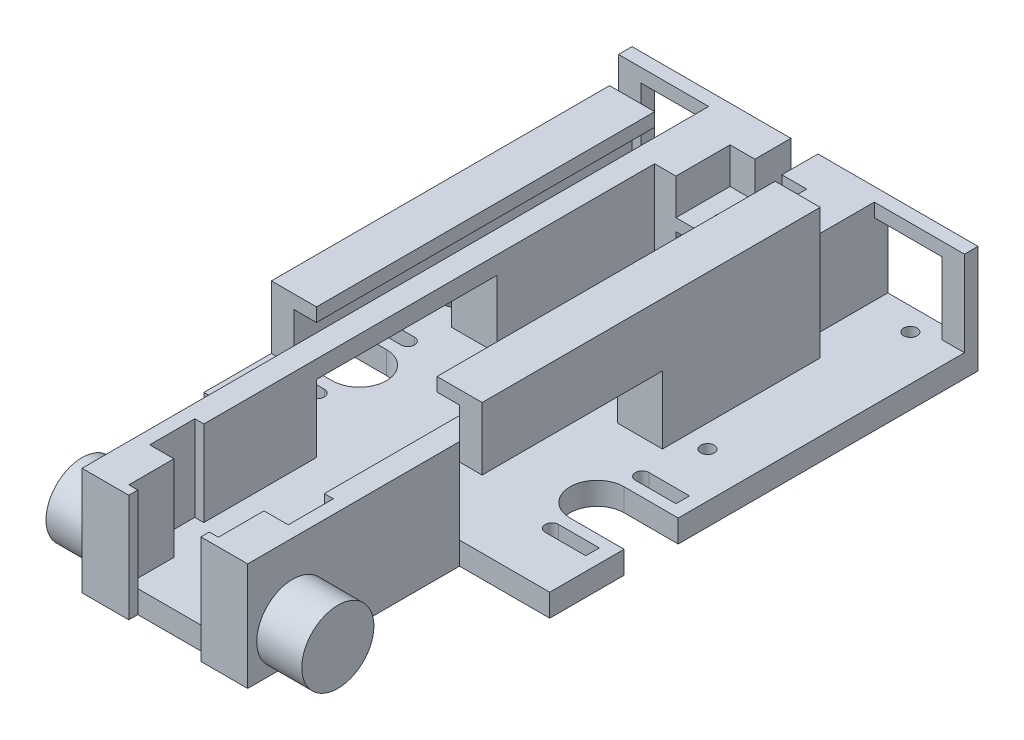
from build123d import *

# Parameters (mm, degrees)
BOSS_EXTRUDE1_DEPTH      = 203.2
SKETCH8_W                = 6.35
SKETCH8_H                = 30.4038
BOSS_EXTRUDE9_DEPTH      = 6.35
BOSS_EXTRUDE10_REACH     = 42.31
SKETCH9_W                = 6.35
SKETCH9_H                = 30.4038
SKETCH4_W                = 6.35
SKETCH4_H                = 30.4038
BOSS_EXTRUDE11_DEPTH     = 6.35
BOSS_EXTRUDE12_REACH     = 42.31
SKETCH10_W               = 6.35
SKETCH10_H               = 30.4038
SKETCH13_W               = 50.8
SKETCH13_H               = 19.05
CUT_EXTRUDE3_DEPTH       = 47.6598
SKETCH14_W               = 44.45
SKETCH14_H               = 6.35
BOSS_EXTRUDE13_DEPTH     = 25.4
SKETCH15_W               = 50.8
SKETCH15_H               = 6.35
BOSS_EXTRUDE14_DEPTH     = 25.4
SKETCH20_W               = 46.6598
SKETCH20_H               = 10.16
CUT_EXTRUDE6_DEPTH       = 6.35
SKETCH28_W               = 25.4
SKETCH28_H               = 6.35
BOSS_EXTRUDE16_DEPTH     = 6.35
SKETCH29_R               = 7.62
CUT_EXTRUDE7_DEPTH       = 6.35
CUT_EXTRUDE8_DEPTH       = 6.35
SKETCH32_R               = 10.16
BOSS_EXTRUDE17_DEPTH     = 12.7
SKETCH33_R               = 10.16
BOSS_EXTRUDE18_DEPTH     = 12.7
SKETCH34_W               = 51.260240893
SKETCH34_H               = 44.363692544
CUT_EXTRUDE9_DEPTH       = 63.5
SKETCH35_W               = 46.6598
SKETCH35_H               = 30.4038
BOSS_EXTRUDE19_DEPTH     = 6.35
SKETCH36_W               = 21.59
SKETCH36_H               = 10.16
CUT_EXTRUDE10_DEPTH      = 6.35
SKETCH37_W               = 25.4
SKETCH37_H               = 6.35
BOSS_EXTRUDE20_DEPTH     = 12.7
SKETCH38_R               = 1.905
CUT_EXTRUDE11_DEPTH      = 12.7
SKETCH44_R               = 1.143
CUT_EXTRUDE15_DEPTH      = 11.16
CUT_EXTRUDE15_DEPTH_BACK = 21.2438
CUT_EXTRUDE13_DEPTH      = 8.35
CUT_EXTRUDE14_DEPTH      = 24.0538
SKETCH47_R               = 3.556
CUT_EXTRUDE16_DEPTH      = 31.4038
CUT_EXTRUDE17_DEPTH      = 13.8938
SKETCH49_W               = 101.6
SKETCH49_H               = 5.0038
BOSS_EXTRUDE23_DEPTH     = 6.35
SKETCH50_W               = 101.6
SKETCH50_H               = 5.0038
BOSS_EXTRUDE24_DEPTH     = 6.35
SKETCH51_R               = 4.7625
SKETCH51_R_2             = 3.556
CUT_EXTRUDE18_DEPTH      = 3.556
SKETCH52_W               = 6.35
SKETCH52_H               = 101.6
SKETCH52_W_2             = 9.525
BOSS_EXTRUDE25_DEPTH     = 15.24
SKETCH53_W               = 59.3598
SKETCH53_H               = 82.55
BOSS_EXTRUDE26_DEPTH     = 3.175
SKETCH54_W               = 6.35
SKETCH54_H               = 20.2438
CUT_EXTRUDE20_DEPTH      = 19.05
SKETCH55_W               = 3.175
SKETCH55_H               = 15.24
CUT_EXTRUDE21_DEPTH      = 101.6
CUT_EXTRUDE23_DEPTH      = 6.35
CUT_EXTRUDE25_DEPTH      = 19.05
SKETCH58_W               = 2.54
SKETCH58_H               = 30.4038
BOSS_EXTRUDE27_DEPTH     = 2.54
SKETCH59_W               = 2.54
SKETCH59_H               = 30.4038
BOSS_EXTRUDE28_DEPTH     = 2.54
SKETCH60_W               = 2.370079739
SKETCH60_H               = 30.4038
BOSS_EXTRUDE29_DEPTH     = 2.54
SKETCH61_W               = 2.54
SKETCH61_H               = 30.4038
BOSS_EXTRUDE30_DEPTH     = 8.0899
SKETCH62_W               = 2.54
SKETCH62_H               = 30.4038
BOSS_EXTRUDE31_DEPTH     = 8.0899
SKETCH63_W               = 4.2799
SKETCH63_H               = 24.0538
BOSS_EXTRUDE32_DEPTH     = 6.35
SKETCH64_W               = 2.54
SKETCH64_H               = 12.7
CUT_EXTRUDE26_DEPTH      = 24.0538
BOSS_EXTRUDE34_DEPTH     = 19.05
SKETCH66_W               = 59.3598
SKETCH66_H               = 63.5
CUT_EXTRUDE27_DEPTH      = 18.415
SKETCH67_W               = 6.35
SKETCH67_H               = 12.7
BOSS_EXTRUDE35_DEPTH     = 19.05
SKETCH68_W               = 6.35
SKETCH68_H               = 12.7
BOSS_EXTRUDE36_DEPTH     = 19.05
SKETCH69_W               = 6.35
SKETCH69_H               = 63.5
BOSS_EXTRUDE39_DEPTH     = 12.7
SKETCH70_W               = 63.5
SKETCH70_H               = 3.81
BOSS_EXTRUDE40_DEPTH     = 6.35
SKETCH71_W               = 63.5
SKETCH71_H               = 3.81
BOSS_EXTRUDE41_DEPTH     = 6.35
SKETCH72_R               = 1.086486674
SKETCH72_R_2             = 1.143
CUT_EXTRUDE29_DEPTH      = 21.2438
SKETCH73_R               = 1.143
BOSS_EXTRUDE42_DEPTH     = 20.2438
SKETCH74_W               = 21.59
SKETCH74_H               = 1.6
CUT_EXTRUDE30_DEPTH      = 10.16
SKETCH75_W               = 46.6598
SKETCH75_H               = 30.4038
BOSS_EXTRUDE43_DEPTH     = 10.16
CUT_EXTRUDE32_DEPTH      = 10.16
SKETCH78_W               = 25.4
SKETCH78_H               = 6.35
BOSS_EXTRUDE44_DEPTH     = 57.15
SKETCH79_R               = 1.905
CUT_EXTRUDE33_DEPTH      = 37.7538
CUT_EXTRUDE33_DEPTH_BACK = 7.35
SKETCH80_W               = 44.45
SKETCH80_H               = 6.35
CUT_EXTRUDE34_DEPTH      = 25.4
SKETCH81_W               = 44.45
SKETCH81_H               = 6.35
CUT_EXTRUDE35_DEPTH      = 25.4
SKETCH82_W               = 6.35
SKETCH82_H               = 3.81
BOSS_EXTRUDE47_DEPTH     = 24.0538
SKETCH83_W               = 3.81
SKETCH83_H               = 3.81
BOSS_EXTRUDE48_DEPTH     = 19.05
SKETCH84_W               = 3.81
SKETCH84_H               = 3.81
BOSS_EXTRUDE49_DEPTH     = 19.05
SKETCH85_W               = 25.4
SKETCH85_H               = 6.35
BOSS_EXTRUDE50_DEPTH     = 44.45
SKETCH86_W               = 25.4
SKETCH86_H               = 6.35
BOSS_EXTRUDE51_DEPTH     = 44.45
BOSS_EXTRUDE52_DEPTH     = 31.75


with BuildPart() as part:
    # Sketch1 → Boss-Extrude1 (new body)
    with BuildSketch(Plane.XY):
        Polygon((0, 0), (33.9598, 0), (33.9598, 24.0538), (40.3098, 24.0538), (40.3098, -6.35), (-6.35, -6.35), (-6.35, 24.0538), (0, 24.0538), align=None)
    extrude(amount=-BOSS_EXTRUDE1_DEPTH)

    # Sketch8 → Boss-Extrude9 (add)
    with BuildSketch(Plane(origin=(0, 0, -203.2), x_dir=(-1, 0, 0), z_dir=(0, 0, -1))):
        with Locations((-37.1348, 8.8519)):
            Rectangle(SKETCH8_W, SKETCH8_H)
        with Locations((3.175, 8.8519)):
            Rectangle(SKETCH8_W, SKETCH8_H)
    extrude(amount=BOSS_EXTRUDE9_DEPTH)

    # Sketch9 → Boss-Extrude10 (add, up to next)
    with BuildSketch(Plane(origin=(0, 0, 0), x_dir=(0, 0, -1), z_dir=(1, 0, 0)), mode=Mode.PRIVATE) as boss_extrude10_sk1:
        with Locations((206.375, 8.8519)):
            Rectangle(SKETCH9_W, SKETCH9_H)
    boss_extrude10_tool1 = extrude(boss_extrude10_sk1.sketch, amount=BOSS_EXTRUDE10_REACH, mode=Mode.PRIVATE) - part.part
    add(boss_extrude10_tool1.solids().sort_by_distance((0, 8.8519, -206.375))[0])

    # Sketch4 → Boss-Extrude11 (add)
    with BuildSketch(Plane.XY):
        with Locations((37.1348, 8.8519)):
            Rectangle(SKETCH4_W, SKETCH4_H)
        with Locations((-3.175, 8.8519)):
            Rectangle(SKETCH4_W, SKETCH4_H)
    extrude(amount=BOSS_EXTRUDE11_DEPTH)

    # Sketch10 → Boss-Extrude12 (add, up to next)
    with BuildSketch(Plane.ZY.offset(-33.9598), mode=Mode.PRIVATE) as boss_extrude12_sk1:
        with Locations((3.175, 8.8519)):
            Rectangle(SKETCH10_W, SKETCH10_H)
    boss_extrude12_tool1 = extrude(boss_extrude12_sk1.sketch, amount=BOSS_EXTRUDE12_REACH, mode=Mode.PRIVATE) - part.part
    add(boss_extrude12_tool1.solids().sort_by_distance((33.9598, 8.8519, 3.175))[0])

    # Sketch13 → Cut-Extrude3 (cut, through all)
    with BuildSketch(Plane(origin=(40.3098, 0, 0), x_dir=(0, 0, -1), z_dir=(1, 0, 0))):
        with Locations((76.2, 9.525)):
            Rectangle(SKETCH13_W, SKETCH13_H)
    extrude(amount=-CUT_EXTRUDE3_DEPTH, mode=Mode.SUBTRACT)

    # Sketch14 → Boss-Extrude13 (add)
    with BuildSketch(Plane(origin=(40.3098, 0, 0), x_dir=(0, 0, -1), z_dir=(1, 0, 0))):
        with Locations((73.025, -3.175)):
            Rectangle(SKETCH14_W, SKETCH14_H)
    extrude(amount=BOSS_EXTRUDE13_DEPTH)

    # Sketch15 → Boss-Extrude14 (add)
    with BuildSketch(Plane.ZY.offset(6.35)):
        with Locations((-76.2, -3.175)):
            Rectangle(SKETCH15_W, SKETCH15_H)
    extrude(amount=BOSS_EXTRUDE14_DEPTH)

    # Sketch20 → Cut-Extrude6 (cut)
    with BuildSketch(Plane(origin=(0, 0, -209.55), x_dir=(-1, 0, 0), z_dir=(0, 0, -1))):
        with Locations((-16.9799, 18.9738)):
            Rectangle(SKETCH20_W, SKETCH20_H)
    extrude(amount=-CUT_EXTRUDE6_DEPTH, mode=Mode.SUBTRACT)

    # Sketch28 → Boss-Extrude16 (add)
    with BuildSketch(Plane(origin=(0, 0, -95.25), x_dir=(-1, 0, 0), z_dir=(0, 0, -1))):
        with Locations((-53.0098, -3.175)):
            Rectangle(SKETCH28_W, SKETCH28_H)
    extrude(amount=BOSS_EXTRUDE16_DEPTH)

    # Sketch29 → Cut-Extrude7 (cut)
    with BuildSketch(Plane(origin=(0, 0, 0), x_dir=(1, 0, 0), z_dir=(0, 1, 0))):
        with Locations((50.4698, 79.375)):
            Circle(SKETCH29_R)
        with Locations((-16.51, 79.375)):
            Circle(SKETCH29_R)
    extrude(amount=-CUT_EXTRUDE7_DEPTH, mode=Mode.SUBTRACT)

    # Sketch30 → Cut-Extrude8 (cut)
    with BuildSketch(Plane(origin=(0, 0, 0), x_dir=(1, 0, 0), z_dir=(0, 1, 0))):
        with BuildLine():
            Line((50.4698, 86.995), (65.7098, 86.995))
            Line((65.7098, 86.995), (65.7098, 71.755))
            Line((65.7098, 71.755), (50.4698, 71.755))
            ThreePointArc((50.4698, 71.755), (58.0898, 79.375), (50.4698, 86.995))
        make_face()
        with BuildLine():
            Line((-31.75, 86.995), (-31.75, 71.755))
            Line((-31.75, 71.755), (-16.51, 71.755))
            ThreePointArc((-16.51, 71.755), (-24.13, 79.375), (-16.51, 86.995))
            Line((-16.51, 86.995), (-31.75, 86.995))
        make_face()
    extrude(amount=-CUT_EXTRUDE8_DEPTH, mode=Mode.SUBTRACT)

    # Sketch32 → Boss-Extrude17 (add)
    with BuildSketch(Plane(origin=(40.3098, 0, 0), x_dir=(0, 0, -1), z_dir=(1, 0, 0))):
        with Locations((3.81, 3.81)):
            Circle(SKETCH32_R)
    extrude(amount=BOSS_EXTRUDE17_DEPTH)

    # Sketch33 → Boss-Extrude18 (add)
    with BuildSketch(Plane.ZY.offset(6.35)):
        with Locations((-3.81, 3.81)):
            Circle(SKETCH33_R)
    extrude(amount=BOSS_EXTRUDE18_DEPTH)

    # Sketch34 → Cut-Extrude9 (cut)
    with BuildSketch(Plane(origin=(0, 0, -209.55), x_dir=(-1, 0, 0), z_dir=(0, 0, -1))):
        with Locations((-14.679679554, 15.831846272)):
            Rectangle(SKETCH34_W, SKETCH34_H)
    extrude(amount=-CUT_EXTRUDE9_DEPTH, mode=Mode.SUBTRACT)

    # Sketch35 → Boss-Extrude19 (add)
    with BuildSketch(Plane(origin=(0, 0, -146.05), x_dir=(-1, 0, 0), z_dir=(0, 0, -1))):
        with Locations((-16.9799, 8.8519)):
            Rectangle(SKETCH35_W, SKETCH35_H)
    extrude(amount=BOSS_EXTRUDE19_DEPTH)

    # Sketch36 → Cut-Extrude10 (cut)
    with BuildSketch(Plane(origin=(0, 0, -152.4), x_dir=(-1, 0, 0), z_dir=(0, 0, -1))):
        with Locations((-16.8148, 18.9738)):
            Rectangle(SKETCH36_W, SKETCH36_H)
    extrude(amount=-CUT_EXTRUDE10_DEPTH, mode=Mode.SUBTRACT)

    # Sketch37 → Boss-Extrude20 (add)
    with BuildSketch(Plane(origin=(0, 0, -101.6), x_dir=(-1, 0, 0), z_dir=(0, 0, -1))):
        with Locations((-53.0098, -3.175)):
            Rectangle(SKETCH37_W, SKETCH37_H)
        with Locations((19.05, -3.175)):
            Rectangle(SKETCH37_W, SKETCH37_H)
    extrude(amount=BOSS_EXTRUDE20_DEPTH)

    # Sketch38 → Cut-Extrude11 (cut)
    with BuildSketch(Plane.XZ.offset(6.35)):
        with Locations((53.0098, -107.95)):
            Circle(SKETCH38_R)
        with Locations((-19.05, -107.95)):
            Circle(SKETCH38_R)
    extrude(amount=-CUT_EXTRUDE11_DEPTH, mode=Mode.SUBTRACT)

    # Sketch44 → Cut-Extrude15 (cut, two sides)
    with BuildSketch(Plane(origin=(0, 13.8938, 0), x_dir=(1, 0, 0), z_dir=(0, 1, 0))) as cut_extrude15_sk:
        with Locations((21.5773, 149.225)):
            Circle(SKETCH44_R)
        with Locations((12.0523, 149.225)):
            Circle(SKETCH44_R)
    extrude(amount=CUT_EXTRUDE15_DEPTH, mode=Mode.SUBTRACT)
    extrude(cut_extrude15_sk.sketch, amount=-CUT_EXTRUDE15_DEPTH_BACK, mode=Mode.SUBTRACT)

    # Sketch39 → Cut-Extrude13 (cut)
    with BuildSketch(Plane(origin=(0, 0, 0), x_dir=(1, 0, 0), z_dir=(0, 1, 0))):
        with BuildLine():
            Line((61.8998, 68.58), (50.4698, 68.58))
            ThreePointArc((50.4698, 68.58), (48.5648, 66.675), (50.4698, 64.77))
            Line((50.4698, 64.77), (61.8998, 64.77))
            Line((61.8998, 64.77), (61.8998, 68.58))
        make_face()
        with BuildLine():
            Line((61.8998, 93.98), (50.4698, 93.98))
            ThreePointArc((50.4698, 93.98), (48.5648, 92.075), (50.4698, 90.17))
            Line((50.4698, 90.17), (61.8998, 90.17))
            Line((61.8998, 90.17), (61.8998, 93.98))
        make_face()
        with BuildLine():
            Line((-27.0002, 93.98), (-27.0002, 90.17))
            Line((-27.0002, 90.17), (-15.5702, 90.17))
            ThreePointArc((-15.5702, 90.17), (-13.6652, 92.075), (-15.5702, 93.98))
            Line((-15.5702, 93.98), (-27.0002, 93.98))
        make_face()
        with BuildLine():
            Line((-27.0002, 64.77), (-15.5702, 64.77))
            ThreePointArc((-15.5702, 64.77), (-13.6652, 66.675), (-15.5702, 68.58))
            Line((-15.5702, 68.58), (-27.0002, 68.58))
            Line((-27.0002, 68.58), (-27.0002, 64.77))
        make_face()
    extrude(amount=-CUT_EXTRUDE13_DEPTH, mode=Mode.SUBTRACT)

    # Sketch40 → Cut-Extrude14 (cut)
    with BuildSketch(Plane(origin=(0, 24.0538, 0), x_dir=(1, 0, 0), z_dir=(0, 1, 0))):
        Polygon((4.2799, -6.35), (16.9799, -6.35), (29.6799, -6.35), (29.6799, 0), (4.2799, 0), align=None)
    extrude(amount=-CUT_EXTRUDE14_DEPTH, mode=Mode.SUBTRACT)

    # Sketch47 → Cut-Extrude16 (cut, through all)
    with BuildSketch(Plane(origin=(0, -6.35, 0), x_dir=(-1, 0, 0), z_dir=(0, -1, 0))):
        with Locations((-16.9799, 142.24)):
            Circle(SKETCH47_R)
    extrude(amount=-CUT_EXTRUDE16_DEPTH, mode=Mode.SUBTRACT)

    # Sketch48 → Cut-Extrude17 (cut)
    with BuildSketch(Plane(origin=(0, 13.8938, 0), x_dir=(1, 0, 0), z_dir=(0, 1, 0))):
        with BuildLine():
            Line((21.5773, 146.05), (12.0523, 146.05))
            ThreePointArc((12.0523, 146.05), (16.8148, 148.022692091), (21.5773, 146.05))
        make_face()
    extrude(amount=-CUT_EXTRUDE17_DEPTH, mode=Mode.SUBTRACT)

    # Sketch49 → Boss-Extrude23 (add)
    with BuildSketch(Plane.ZY.offset(6.35)):
        with Locations((-101.6, 21.5519)):
            Rectangle(SKETCH49_W, SKETCH49_H)
    extrude(amount=BOSS_EXTRUDE23_DEPTH)

    # Sketch50 → Boss-Extrude24 (add)
    with BuildSketch(Plane(origin=(40.3098, 0, 0), x_dir=(0, 0, -1), z_dir=(1, 0, 0))):
        with Locations((101.6, 21.5519)):
            Rectangle(SKETCH50_W, SKETCH50_H)
    extrude(amount=BOSS_EXTRUDE24_DEPTH)

    # Sketch51 → Cut-Extrude18 (cut)
    with BuildSketch(Plane(origin=(0, 0, 0), x_dir=(1, 0, 0), z_dir=(0, 1, 0))):
        with Locations((16.9799, 142.24)):
            Circle(SKETCH51_R)
        with Locations((16.9799, 142.24)):
            Circle(SKETCH51_R_2, mode=Mode.SUBTRACT)
    extrude(amount=-CUT_EXTRUDE18_DEPTH, mode=Mode.SUBTRACT)

    # Sketch52 → Boss-Extrude25 (add)
    with BuildSketch(Plane(origin=(0, 24.0538, 0), x_dir=(1, 0, 0), z_dir=(0, 1, 0))):
        with Locations((-9.525, 101.6)):
            Rectangle(SKETCH52_W, SKETCH52_H)
        with Locations((41.8973, 101.6)):
            Rectangle(SKETCH52_W_2, SKETCH52_H)
    extrude(amount=BOSS_EXTRUDE25_DEPTH)

    # Sketch53 → Boss-Extrude26 (add)
    with BuildSketch(Plane(origin=(0, 39.2938, 0), x_dir=(1, 0, 0), z_dir=(0, 1, 0))):
        with Locations((16.9799, 92.075)):
            Rectangle(SKETCH53_W, SKETCH53_H)
    extrude(amount=BOSS_EXTRUDE26_DEPTH)

    # Sketch54 → Cut-Extrude20 (cut)
    with BuildSketch(Plane(origin=(0, 0, -152.4), x_dir=(-1, 0, 0), z_dir=(0, 0, -1))):
        with Locations((9.525, 29.1719)):
            Rectangle(SKETCH54_W, SKETCH54_H)
        with Locations((-43.4848, 29.1719)):
            Rectangle(SKETCH54_W, SKETCH54_H)
    extrude(amount=-CUT_EXTRUDE20_DEPTH, mode=Mode.SUBTRACT)

    # Sketch55 → Cut-Extrude21 (cut)
    with BuildSketch(Plane(origin=(0, 0, -152.4), x_dir=(-1, 0, 0), z_dir=(0, 0, -1))):
        with Locations((-38.7223, 31.6738)):
            Rectangle(SKETCH55_W, SKETCH55_H)
    extrude(amount=-CUT_EXTRUDE21_DEPTH, mode=Mode.SUBTRACT)

    # Sketch56 → Cut-Extrude23 (cut)
    with BuildSketch(Plane(origin=(0, 0, -152.4), x_dir=(-1, 0, 0), z_dir=(0, 0, -1))):
        Polygon((-6.0198, 8.89), (-6.0198, 10.49), (-27.6098, 10.49), (-27.6098, 8.89), (-16.9799, 8.89), align=None)
    extrude(amount=-CUT_EXTRUDE23_DEPTH, mode=Mode.SUBTRACT)

    # Sketch57 → Cut-Extrude25 (cut)
    with BuildSketch(Plane(origin=(0, 0, -133.35), x_dir=(-1, 0, 0), z_dir=(0, 0, -1))):
        Polygon((6.35, 19.05), (12.7, 19.05), (12.7, 42.4688), (-46.6598, 42.4688), (-46.6598, 19.05), (-40.3098, 19.05), (-40.3098, 39.2938), (6.35, 39.2938), align=None)
    extrude(amount=-CUT_EXTRUDE25_DEPTH, mode=Mode.SUBTRACT)

    # Sketch58 → Boss-Extrude27 (add)
    with BuildSketch(Plane.XY.offset(6.35)):
        with Locations((30.9499, 8.8519)):
            Rectangle(SKETCH58_W, SKETCH58_H)
        with Locations((3.0099, 8.8519)):
            Rectangle(SKETCH58_W, SKETCH58_H)
    extrude(amount=BOSS_EXTRUDE27_DEPTH)

    # Sketch59 → Boss-Extrude28 (add)
    with BuildSketch(Plane(origin=(4.2799, 0, 0), x_dir=(0, 0, -1), z_dir=(1, 0, 0))):
        with Locations((-7.62, 8.8519)):
            Rectangle(SKETCH59_W, SKETCH59_H)
    extrude(amount=BOSS_EXTRUDE28_DEPTH)

    # Sketch60 → Boss-Extrude29 (add)
    with BuildSketch(Plane.ZY.offset(-29.6799)):
        with Locations((7.70496013, 8.8519)):
            Rectangle(SKETCH60_W, SKETCH60_H)
    extrude(amount=BOSS_EXTRUDE29_DEPTH)

    # Sketch61 → Boss-Extrude30 (add)
    with BuildSketch(Plane.ZY.offset(-1.7399)):
        with Locations((7.62, 8.8519)):
            Rectangle(SKETCH61_W, SKETCH61_H)
    extrude(amount=BOSS_EXTRUDE30_DEPTH)

    # Sketch62 → Boss-Extrude31 (add)
    with BuildSketch(Plane(origin=(32.2199, 0, 0), x_dir=(0, 0, -1), z_dir=(1, 0, 0))):
        with Locations((-7.62, 8.8519)):
            Rectangle(SKETCH62_W, SKETCH62_H)
    extrude(amount=BOSS_EXTRUDE31_DEPTH)

    # Sketch63 → Boss-Extrude32 (add)
    with BuildSketch(Plane(origin=(0, 0, 0), x_dir=(-1, 0, 0), z_dir=(0, 0, -1))):
        with Locations((-2.13995, 12.0269)):
            Rectangle(SKETCH63_W, SKETCH63_H)
        with Locations((-31.81985, 12.0269)):
            Rectangle(SKETCH63_W, SKETCH63_H)
    extrude(amount=BOSS_EXTRUDE32_DEPTH)

    # Sketch64 → Cut-Extrude26 (cut)
    with BuildSketch(Plane(origin=(0, 24.0538, 0), x_dir=(1, 0, 0), z_dir=(0, 1, 0))):
        with Locations((-1.27, 12.7)):
            Rectangle(SKETCH64_W, SKETCH64_H)
        with Locations((35.2298, 12.7)):
            Rectangle(SKETCH64_W, SKETCH64_H)
    extrude(amount=-CUT_EXTRUDE26_DEPTH, mode=Mode.SUBTRACT)

    # Sketch65 → Boss-Extrude34 (add)
    with BuildSketch(Plane(origin=(0, 0, -152.4), x_dir=(-1, 0, 0), z_dir=(0, 0, -1))):
        Polygon((6.35, 24.0538), (-6.0198, 24.0538), (-6.0198, 13.8938), (-27.6098, 13.8938), (-27.6098, 24.0538), (-40.3098, 24.0538), (-40.3098, -6.35), (6.35, -6.35), align=None)
    extrude(amount=BOSS_EXTRUDE34_DEPTH)

    # Sketch66 → Cut-Extrude27 (cut)
    with BuildSketch(Plane(origin=(0, 42.4688, 0), x_dir=(1, 0, 0), z_dir=(0, 1, 0))):
        with Locations((16.9799, 82.55)):
            Rectangle(SKETCH66_W, SKETCH66_H)
    extrude(amount=-CUT_EXTRUDE27_DEPTH, mode=Mode.SUBTRACT)

    # Sketch67 → Boss-Extrude35 (add)
    with BuildSketch(Plane.XZ.offset(-19.05)):
        with Locations((43.4848, -107.95)):
            Rectangle(SKETCH67_W, SKETCH67_H)
    extrude(amount=BOSS_EXTRUDE35_DEPTH)

    # Sketch68 → Boss-Extrude36 (add)
    with BuildSketch(Plane.XZ.offset(-19.05)):
        with Locations((-9.525, -107.95)):
            Rectangle(SKETCH68_W, SKETCH68_H)
    extrude(amount=BOSS_EXTRUDE36_DEPTH)

    # Sketch69 → Boss-Extrude39 (add)
    with BuildSketch(Plane(origin=(0, 24.0538, 0), x_dir=(1, 0, 0), z_dir=(0, 1, 0))):
        with Locations((43.4848, 82.55)):
            Rectangle(SKETCH69_W, SKETCH69_H)
        with Locations((-9.525, 82.55)):
            Rectangle(SKETCH69_W, SKETCH69_H)
    extrude(amount=BOSS_EXTRUDE39_DEPTH)

    # Sketch70 → Boss-Extrude40 (add)
    with BuildSketch(Plane.ZY.offset(-40.3098)):
        with Locations((-82.55, 34.8488)):
            Rectangle(SKETCH70_W, SKETCH70_H)
    extrude(amount=BOSS_EXTRUDE40_DEPTH)

    # Sketch71 → Boss-Extrude41 (add)
    with BuildSketch(Plane(origin=(-6.35, 0, 0), x_dir=(0, 0, -1), z_dir=(1, 0, 0))):
        with Locations((82.55, 34.8488)):
            Rectangle(SKETCH71_W, SKETCH71_H)
    extrude(amount=BOSS_EXTRUDE41_DEPTH)

    # Sketch72 → Cut-Extrude29 (cut, through all)
    with BuildSketch(Plane(origin=(0, 13.8938, 0), x_dir=(1, 0, 0), z_dir=(0, 1, 0))):
        with Locations((12.0523, 152.323550936)):
            Circle(SKETCH72_R)
        with Locations((21.5773, 152.323550936)):
            Circle(SKETCH72_R_2)
    extrude(amount=-CUT_EXTRUDE29_DEPTH, mode=Mode.SUBTRACT)

    # Sketch73 → Boss-Extrude42 (add)
    with BuildSketch(Plane(origin=(0, 13.8938, 0), x_dir=(1, 0, 0), z_dir=(0, 1, 0))):
        with Locations((12.0523, 149.225)):
            Circle(SKETCH73_R)
        with Locations((21.5773, 149.225)):
            Circle(SKETCH73_R)
    extrude(amount=-BOSS_EXTRUDE42_DEPTH)

    # Sketch74 → Cut-Extrude30 (cut)
    with BuildSketch(Plane.XY.offset(-146.05)):
        with Locations((16.8148, 9.69)):
            Rectangle(SKETCH74_W, SKETCH74_H)
    extrude(amount=-CUT_EXTRUDE30_DEPTH, mode=Mode.SUBTRACT)

    # Sketch75 → Boss-Extrude43 (add)
    with BuildSketch(Plane(origin=(0, 0, -171.45), x_dir=(-1, 0, 0), z_dir=(0, 0, -1))):
        with Locations((-16.9799, 8.8519)):
            Rectangle(SKETCH75_W, SKETCH75_H)
    extrude(amount=-BOSS_EXTRUDE43_DEPTH)

    # Sketch76 → Cut-Extrude32 (cut)
    with BuildSketch(Plane(origin=(0, 24.0538, 0), x_dir=(1, 0, 0), z_dir=(0, 1, 0))):
        Polygon((16.8148, 161.29), (20.6248, 161.29), (20.6248, 171.45), (13.0048, 171.45), (13.0048, 161.29), align=None)
    extrude(amount=-CUT_EXTRUDE32_DEPTH, mode=Mode.SUBTRACT)

    # Sketch78 → Boss-Extrude44 (add)
    with BuildSketch(Plane(origin=(0, 0, -114.3), x_dir=(-1, 0, 0), z_dir=(0, 0, -1))):
        with Locations((-53.0098, -3.175)):
            Rectangle(SKETCH78_W, SKETCH78_H)
        with Locations((19.05, -3.175)):
            Rectangle(SKETCH78_W, SKETCH78_H)
    extrude(amount=BOSS_EXTRUDE44_DEPTH)

    # Sketch79 → Cut-Extrude33 (cut, two sides)
    with BuildSketch(Plane(origin=(0, 0, 0), x_dir=(1, 0, 0), z_dir=(0, 1, 0))) as cut_extrude33_sk:
        with Locations((-19.05, 165.1)):
            Circle(SKETCH79_R)
        with Locations((53.0098, 165.1)):
            Circle(SKETCH79_R)
    extrude(amount=CUT_EXTRUDE33_DEPTH, mode=Mode.SUBTRACT)
    extrude(cut_extrude33_sk.sketch, amount=-CUT_EXTRUDE33_DEPTH_BACK, mode=Mode.SUBTRACT)

    # Sketch80 → Cut-Extrude34 (cut)
    with BuildSketch(Plane(origin=(65.7098, 0, 0), x_dir=(0, 0, -1), z_dir=(1, 0, 0))):
        with Locations((136.525, -3.175)):
            Rectangle(SKETCH80_W, SKETCH80_H)
    extrude(amount=-CUT_EXTRUDE34_DEPTH, mode=Mode.SUBTRACT)

    # Sketch81 → Cut-Extrude35 (cut)
    with BuildSketch(Plane.ZY.offset(31.75)):
        with Locations((-136.525, -3.175)):
            Rectangle(SKETCH81_W, SKETCH81_H)
    extrude(amount=-CUT_EXTRUDE35_DEPTH, mode=Mode.SUBTRACT)

    # Sketch82 → Boss-Extrude47 (add)
    with BuildSketch(Plane(origin=(0, 0, 0), x_dir=(1, 0, 0), z_dir=(0, 1, 0))):
        with Locations((-28.575, 169.545)):
            Rectangle(SKETCH82_W, SKETCH82_H)
        with Locations((62.5348, 169.545)):
            Rectangle(SKETCH82_W, SKETCH82_H)
    extrude(amount=BOSS_EXTRUDE47_DEPTH)

    # Sketch83 → Boss-Extrude48 (add)
    with BuildSketch(Plane.ZY.offset(-59.3598)):
        with Locations((-169.545, 22.1488)):
            Rectangle(SKETCH83_W, SKETCH83_H)
    extrude(amount=BOSS_EXTRUDE48_DEPTH)

    # Sketch84 → Boss-Extrude49 (add)
    with BuildSketch(Plane(origin=(-25.4, 0, 0), x_dir=(0, 0, -1), z_dir=(1, 0, 0))):
        with Locations((169.545, 22.1488)):
            Rectangle(SKETCH84_W, SKETCH84_H)
    extrude(amount=BOSS_EXTRUDE49_DEPTH)

    # Sketch85 → Boss-Extrude50 (add)
    with BuildSketch(Plane(origin=(0, 0, -114.3), x_dir=(-1, 0, 0), z_dir=(0, 0, -1))):
        with Locations((19.05, -3.175)):
            Rectangle(SKETCH85_W, SKETCH85_H)
    extrude(amount=BOSS_EXTRUDE50_DEPTH)

    # Sketch86 → Boss-Extrude51 (add)
    with BuildSketch(Plane(origin=(0, 0, -114.3), x_dir=(-1, 0, 0), z_dir=(0, 0, -1))):
        with Locations((-53.0098, -3.175)):
            Rectangle(SKETCH86_W, SKETCH86_H)
    extrude(amount=BOSS_EXTRUDE51_DEPTH)

    # Sketch87 → Boss-Extrude52 (add)
    with BuildSketch(Plane(origin=(0, 0, -114.3), x_dir=(-1, 0, 0), z_dir=(0, 0, -1))):
        Polygon((-33.9598, 36.7538), (-46.6598, 36.7538), (-46.6598, 0), (-40.3098, 0), (-40.3098, 32.9438), (-33.9598, 32.9438), align=None)
        Polygon((0, 36.7538), (12.7, 36.7538), (12.7, 0), (6.35, 0), (6.35, 32.9438), (0, 32.9438), align=None)
    extrude(amount=BOSS_EXTRUDE52_DEPTH)


solid = part.part
